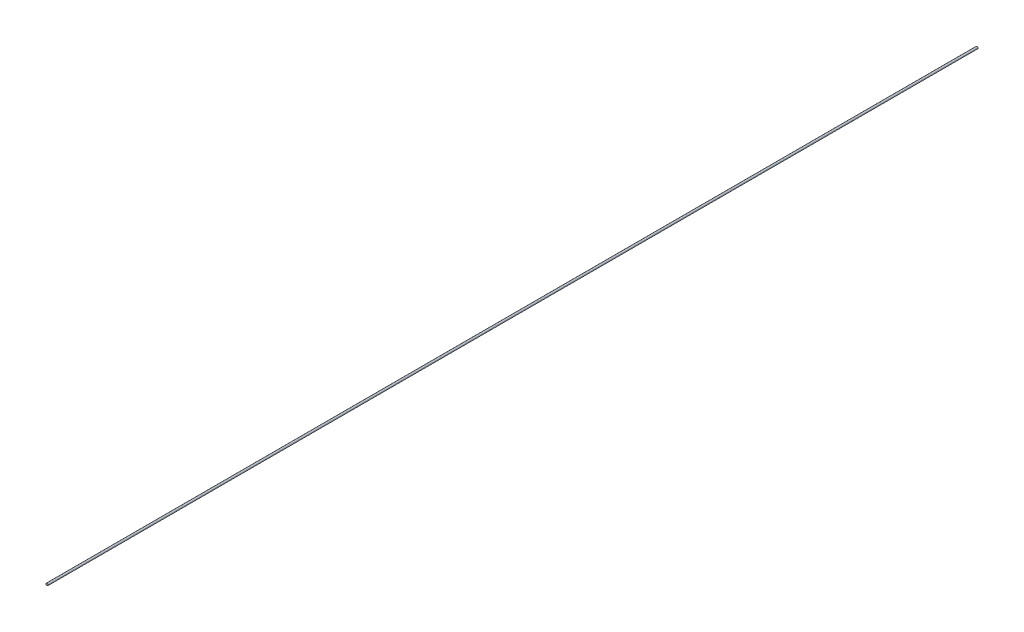
from build123d import *

# Parameters (mm, degrees)
SKETCH2_R                = 2.75
SKETCH2_R_2              = 0.5
BOSS_EXTRUDE1_DEPTH      = 1229.528888
BOSS_EXTRUDE1_DEPTH_BACK = 1229.528888


with BuildPart() as part:
    # Sketch2 → Boss-Extrude1 (new body, two sides)
    with BuildSketch(Plane.XY) as boss_extrude1_sk:
        Circle(SKETCH2_R)
        Circle(SKETCH2_R_2, mode=Mode.SUBTRACT)
    extrude(amount=BOSS_EXTRUDE1_DEPTH)
    extrude(boss_extrude1_sk.sketch, amount=-BOSS_EXTRUDE1_DEPTH_BACK)


solid = part.part
